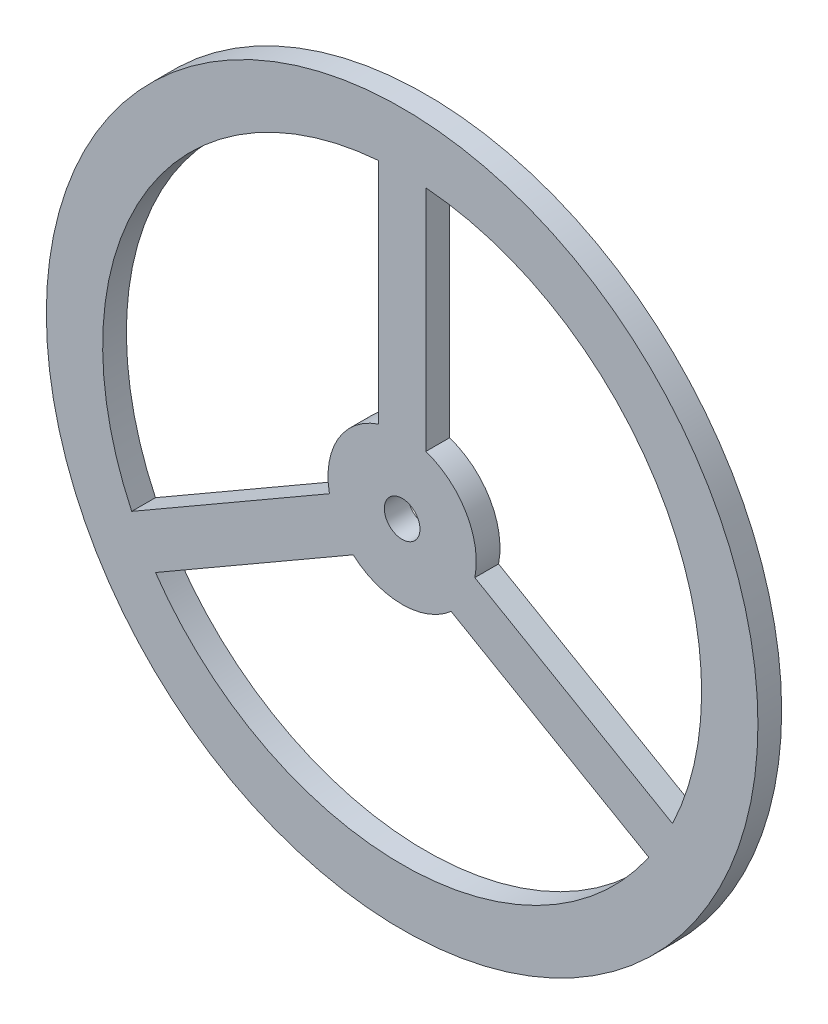
from build123d import *

# Parameters (mm, degrees)
SKETCH_1_R      = 60
SKETCH_1_R_2    = 3
EXTRUDE_1_DEPTH = 4


with BuildPart() as part:
    # 草图1 → 凸台-拉伸1 (new body)
    with BuildSketch(Plane.XY):
        Circle(SKETCH_1_R)
        Circle(SKETCH_1_R_2, mode=Mode.SUBTRACT)
        with BuildLine():
            Line((-4, 11.842719282), (-4, 50.341334905))
            ThreePointArc((-4, 50.341334905), (-43.734282891, 25.25), (-45.596874888, -21.706565837))
            Line((-45.596874888, -21.706565837), (-12.256095748, -2.457258026))
            ThreePointArc((-12.256095748, -2.457258026), (-10.825317547, 6.25), (-4, 11.842719282))
        make_face(mode=Mode.SUBTRACT)
        with BuildLine():
            Line((4, 11.842719282), (4, 50.341334905))
            ThreePointArc((4, 50.341334905), (43.734282891, 25.25), (45.596874888, -21.706565837))
            Line((45.596874888, -21.706565837), (12.256095748, -2.457258026))
            ThreePointArc((12.256095748, -2.457258026), (10.825317547, 6.25), (4, 11.842719282))
        make_face(mode=Mode.SUBTRACT)
        with BuildLine():
            Line((8.256095748, -9.385461256), (41.596874888, -28.634769068))
            ThreePointArc((41.596874888, -28.634769068), (0, -50.5), (-41.596874888, -28.634769068))
            Line((-41.596874888, -28.634769068), (-8.256095748, -9.385461256))
            ThreePointArc((-8.256095748, -9.385461256), (0, -12.5), (8.256095748, -9.385461256))
        make_face(mode=Mode.SUBTRACT)
    extrude(amount=EXTRUDE_1_DEPTH)


solid = part.part
